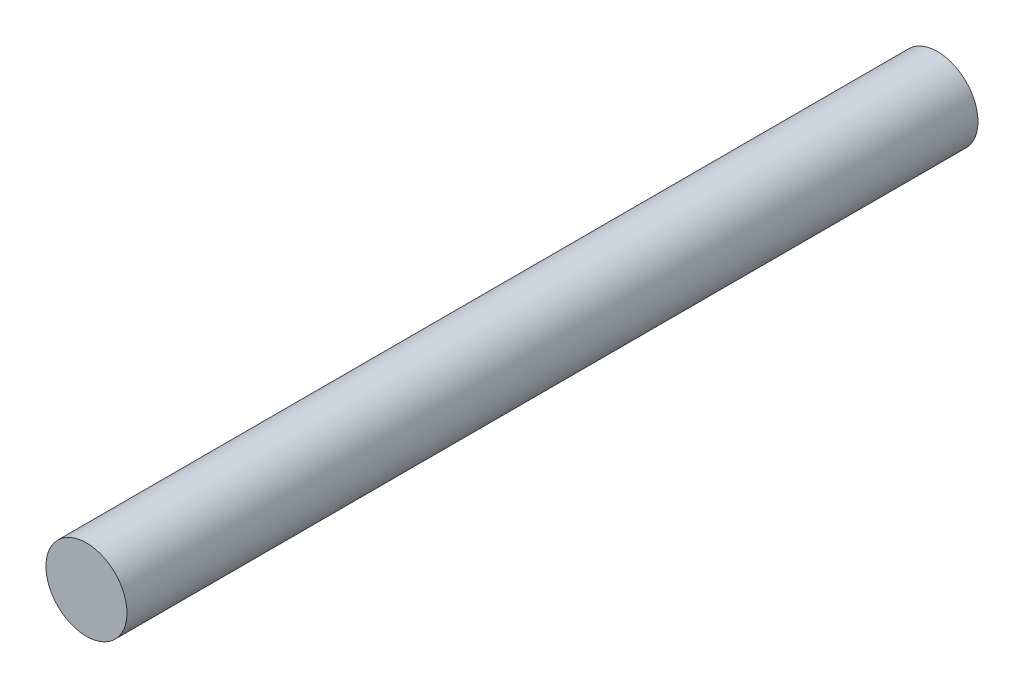
from build123d import *

# Parameters (mm, degrees)
ESQUISSE1_W = 1
ESQUISSE1_H = 21


with BuildPart() as part:
    # Esquisse1 → Révolution1 (revolve)
    with BuildSketch(Plane(origin=(0, 0, 0), x_dir=(1, 0, 0), z_dir=(0, 1, 0))):
        with Locations((0.5, -10.5)):
            Rectangle(ESQUISSE1_W, ESQUISSE1_H)
    revolve(axis=Axis((0, 0, 0), (0, 0, 1)))


solid = part.part
